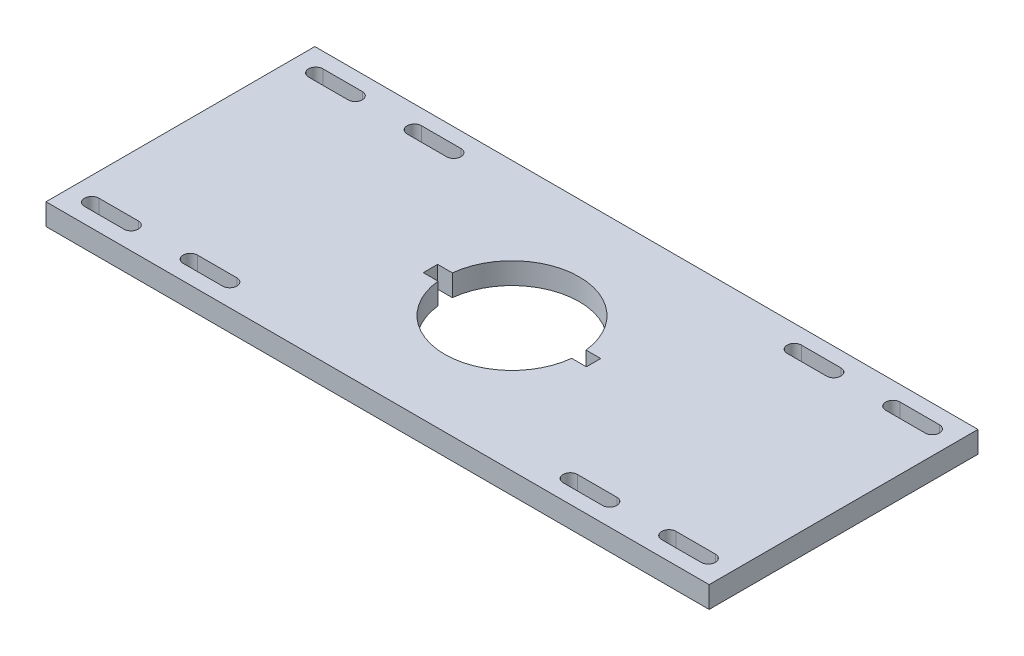
from build123d import *

# Parameters (mm, degrees)
SKETCH1_W           = 370
SKETCH1_H           = 150
BOSS_EXTRUDE1_DEPTH = 12
SKETCH3_R           = 37.5
CUT_EXTRUDE2_DEPTH  = 13
SKETCH6_W           = 91
SKETCH6_H           = 8
CUT_EXTRUDE3_DEPTH  = 13
CUT_EXTRUDE4_DEPTH  = 13


with BuildPart() as part:
    # Sketch1 → Boss-Extrude1 (new body)
    with BuildSketch(Plane(origin=(0, 0, 0), x_dir=(1, 0, 0), z_dir=(0, 1, 0))):
        Rectangle(SKETCH1_W, SKETCH1_H)
    extrude(amount=BOSS_EXTRUDE1_DEPTH)

    # Sketch3 → Cut-Extrude2 (cut, through all)
    with BuildSketch(Plane(origin=(0, 12, 0), x_dir=(1, 0, 0), z_dir=(0, 1, 0))):
        Circle(SKETCH3_R)
    extrude(amount=-CUT_EXTRUDE2_DEPTH, mode=Mode.SUBTRACT)

    # Sketch6 → Cut-Extrude3 (cut, through all)
    with BuildSketch(Plane(origin=(0, 12, 0), x_dir=(1, 0, 0), z_dir=(0, 1, 0))):
        Rectangle(SKETCH6_W, SKETCH6_H)
    extrude(amount=-CUT_EXTRUDE3_DEPTH, mode=Mode.SUBTRACT)

    # Sketch7 → Cut-Extrude4 (cut, through all)
    with BuildSketch(Plane(origin=(0, 12, 0), x_dir=(1, 0, 0), z_dir=(0, 1, 0))):
        with BuildLine():
            Line((-150, -58.5), (-172, -58.5))
            ThreePointArc((-172, -58.5), (-176, -62.5), (-172, -66.5))
            Line((-172, -66.5), (-150, -66.5))
            ThreePointArc((-150, -66.5), (-146, -62.5), (-150, -58.5))
        make_face()
        with BuildLine():
            ThreePointArc((-172, 58.5), (-176, 62.5), (-172, 66.5))
            Line((-172, 66.5), (-150, 66.5))
            ThreePointArc((-150, 66.5), (-146, 62.5), (-150, 58.5))
            Line((-150, 58.5), (-172, 58.5))
        make_face()
        with BuildLine():
            ThreePointArc((-117, 58.5), (-121, 62.5), (-117, 66.5))
            Line((-117, 66.5), (-95, 66.5))
            ThreePointArc((-95, 66.5), (-91, 62.5), (-95, 58.5))
            Line((-95, 58.5), (-117, 58.5))
        make_face()
        with BuildLine():
            Line((-95, -58.5), (-117, -58.5))
            ThreePointArc((-117, -58.5), (-121, -62.5), (-117, -66.5))
            Line((-117, -66.5), (-95, -66.5))
            ThreePointArc((-95, -66.5), (-91, -62.5), (-95, -58.5))
        make_face()
    cut_extrude4 = extrude(amount=-CUT_EXTRUDE4_DEPTH, mode=Mode.SUBTRACT)

    # Mirror1: Cut-Extrude4 across plane
    add(cut_extrude4.mirror(Plane(origin=(0, 0, 0), x_dir=(0, 0, 1), z_dir=(1, 0, 0))), mode=Mode.SUBTRACT)


solid = part.part
